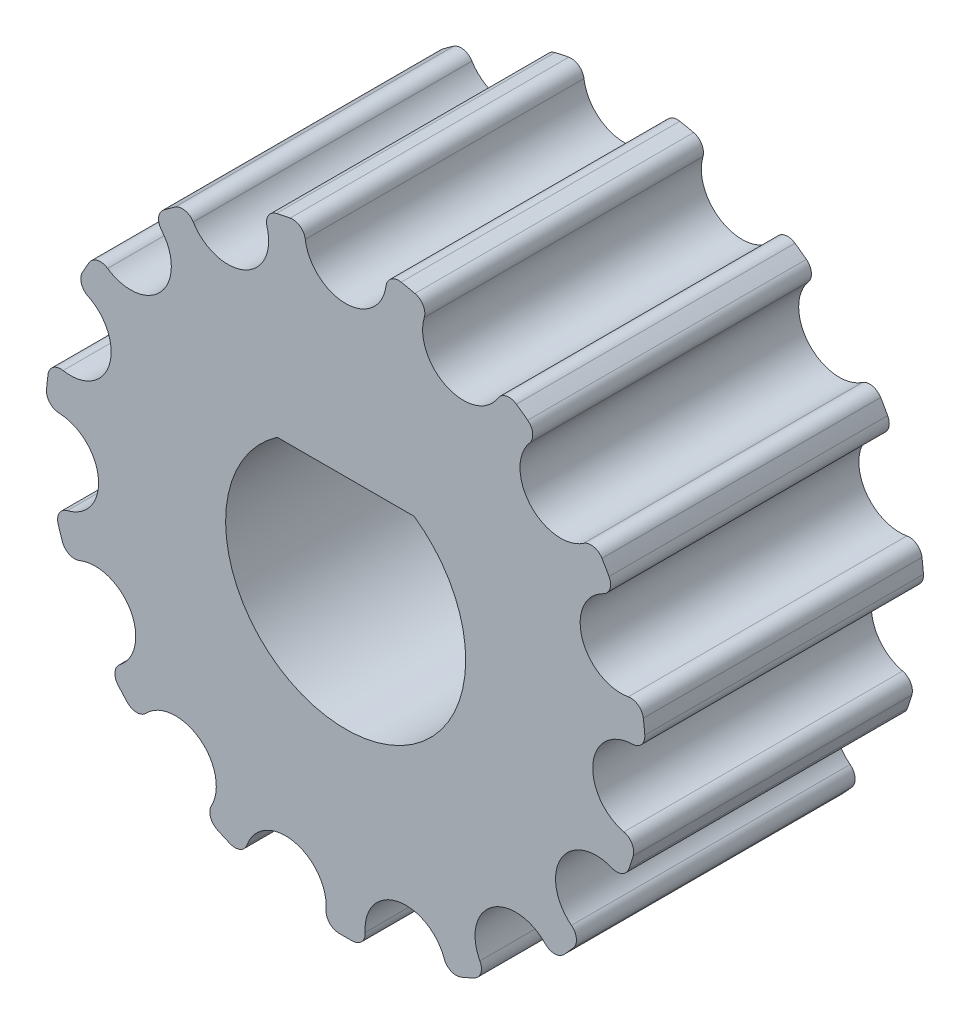
from build123d import *

# Parameters (mm, degrees)
SKIZZE1_R                            = 7
AUFSATZ_LINEAR_AUSTRAGEN1_DEPTH      = 3.25
SCHNITT_LINEAR_AUSTRAGEN1_DEPTH      = 4.25
VERRUNDUNG2_R                        = 0.3
KREISMUSTER1_COUNT                   = 15
VERRUNDUNG2_OF_KREISMUSTER1_R        = 0.3
SCHNITT_LINEAR_AUSTRAGEN2_DEPTH      = 4.2500001
SCHNITT_LINEAR_AUSTRAGEN2_DEPTH_BACK = 4.2500001


with BuildPart() as part:
    # Skizze1 → Aufsatz-Linear austragen1 (new body, symmetric)
    with BuildSketch(Plane.XY):
        Circle(SKIZZE1_R)
    extrude(amount=AUFSATZ_LINEAR_AUSTRAGEN1_DEPTH, both=True)

    # Skizze2 → Schnitt-Linear austragen1 (cut, symmetric)
    with BuildSketch(Plane.XY):
        with BuildLine():
            Line((0.95, 6.75), (0.95, 7))
            Line((0.95, 7), (-0.95, 7))
            Line((-0.95, 7), (-0.95, 6.75))
            ThreePointArc((-0.95, 6.75), (0, 5.8), (0.95, 6.75))
        make_face()
    schnitt_linear_austragen1 = extrude(amount=SCHNITT_LINEAR_AUSTRAGEN1_DEPTH, both=True, mode=Mode.SUBTRACT)

    # Verrundung2
    verrundung2_edges = [part.edges().sort_by_distance(p)[0] for p in [
        (0.95, 6.935236117, 0),
        (-0.95, 6.935236117, 0),
    ]]
    fillet(verrundung2_edges, radius=VERRUNDUNG2_R)

    # Kreismuster1: Schnitt-Linear austragen1 ×15 about axis
    kreismuster1_axis = Axis((0, 0, 0), (0, 0, 1))
    for i in range(1, KREISMUSTER1_COUNT):
        add(schnitt_linear_austragen1.rotate(kreismuster1_axis, i * 360 / KREISMUSTER1_COUNT), mode=Mode.SUBTRACT)

    # Verrundung2 of Kreismuster1
    verrundung2_of_kreismuster1_edges = [part.edges().sort_by_distance(p)[0] for p in [
        (-1.952946472, 6.722053263, 0),
        (-3.688682842, 5.949253642, 0),
        (-4.518210758, 5.346566332, 0),
        (-5.78955891, 3.934591164, 0),
        (-6.302235357, 3.046609511, 0),
        (-6.889367646, 1.23960213, 0),
        (-6.996546208, 0.219866227, 0),
        (-6.797942128, -1.669725374, 0),
        (-6.481090659, -2.644893925, 0),
        (-5.531090659, -4.290342192, 0),
        (-4.844995655, -5.052327889, 0),
        (-3.307863366, -6.169119868, 0),
        (-2.371156888, -6.586168462, 0),
        (-0.512676447, -6.981200675, 0),
        (0.512676447, -6.981200675, 0),
        (2.371156888, -6.586168462, 0),
        (3.307863366, -6.169119868, 0),
        (4.844995655, -5.052327889, 0),
        (5.531090659, -4.290342192, 0),
        (6.481090659, -2.644893925, 0),
        (6.797942128, -1.669725374, 0),
        (6.996546208, 0.219866227, 0),
        (6.889367646, 1.23960213, 0),
        (6.302235357, 3.046609511, 0),
        (5.78955891, 3.934591164, 0),
        (4.518210758, 5.346566332, 0),
        (3.688682842, 5.949253642, 0),
        (1.952946472, 6.722053263, 0),
    ]]
    fillet(verrundung2_of_kreismuster1_edges, radius=VERRUNDUNG2_OF_KREISMUSTER1_R)

    # Skizze3 → Schnitt-Linear austragen2 (cut, two sides)
    with BuildSketch(Plane.XY) as schnitt_linear_austragen2_sk:
        with BuildLine():
            Line((1.596871942, 2.3), (-1.596871942, 2.3))
            ThreePointArc((-1.596871942, 2.3), (0, -2.8), (1.596871942, 2.3))
        make_face()
    extrude(amount=SCHNITT_LINEAR_AUSTRAGEN2_DEPTH, mode=Mode.SUBTRACT)
    extrude(schnitt_linear_austragen2_sk.sketch, amount=-SCHNITT_LINEAR_AUSTRAGEN2_DEPTH_BACK, mode=Mode.SUBTRACT)


solid = part.part
